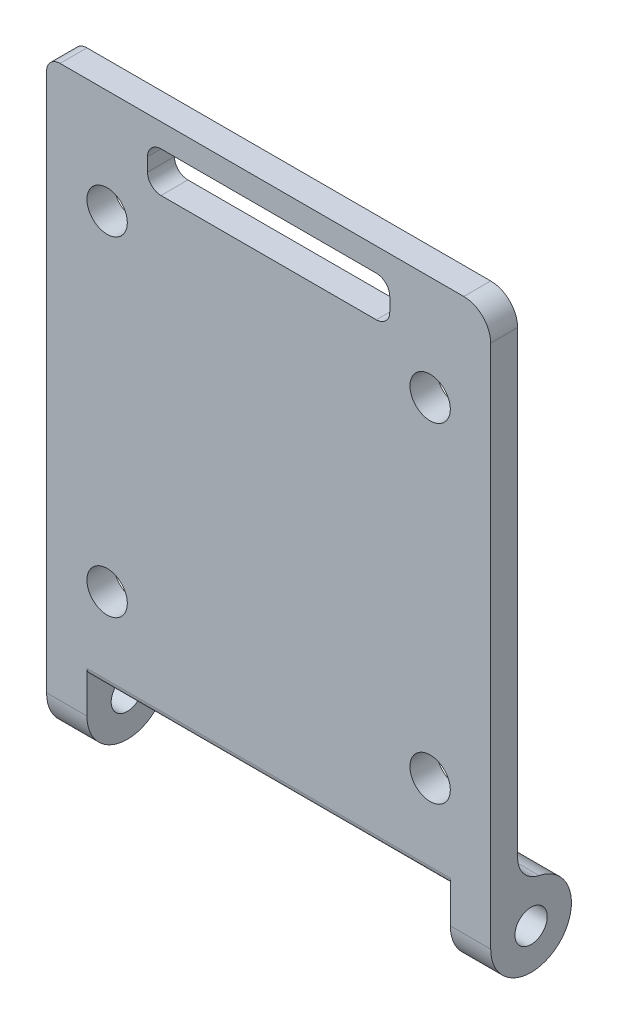
from build123d import *
from OCP.BRepFilletAPI import BRepFilletAPI_MakeFillet

# Parameters (mm, degrees)
SKETCH1_W               = 33
SKETCH1_H               = 40
BOSS_EXTRUDE1_DEPTH     = 1
SKETCH3_R               = 1.2
BOSS_EXTRUDE2_DEPTH     = 3
BOSS_EXTRUDE3_START     = -3
SKETCH4_R               = 1.2
BOSS_EXTRUDE3_DEPTH     = 3
CUT_EXTRUDE1_DEPTH      = 30.550803712
CUT_EXTRUDE1_DEPTH_BACK = 30.550803712
SKETCH6_R               = 1.5
SKETCH6_W               = 18
SKETCH6_H               = 3
FILLET4_R1              = 2
FILLET4_R2              = 1
CUT_EXTRUDE2_DEPTH      = 27
FILLET5_R               = 0.5


with BuildPart() as part:
    # Sketch1 → Boss-Extrude1 (new, symmetric)
    with BuildSketch(Plane.XY):
        Rectangle(SKETCH1_W, SKETCH1_H)
    extrude(amount=BOSS_EXTRUDE1_DEPTH, both=True)

    # Sketch3 → Boss-Extrude2 (add)
    with BuildSketch(Plane(origin=(16.5, 0, 0), x_dir=(0, 0, -1), z_dir=(1, 0, 0))):
        with BuildLine():
            Line((-1, -20), (-1, -21))
            ThreePointArc((-1, -21), (4.449489743, -22.732050808), (1, -18.171572875))
            Line((1, -18.171572875), (-1, -20))
        make_face()
        with Locations((2, -21)):
            Circle(SKETCH3_R, mode=Mode.SUBTRACT)
    extrude(amount=-BOSS_EXTRUDE2_DEPTH)

    # Sketch4 → Boss-Extrude3 (add)
    with BuildSketch(Plane.ZY.offset(16.5).offset(BOSS_EXTRUDE3_START)):
        with BuildLine():
            Line((1, -20), (1, -21))
            ThreePointArc((1, -21), (-4.449489743, -22.732050808), (-1, -18.171572875))
            Line((-1, -18.171572875), (1, -20))
        make_face()
        with Locations(Location((-2, -21, 0), (0, 0, 180))):
            Circle(SKETCH4_R, mode=Mode.SUBTRACT)
    extrude(amount=BOSS_EXTRUDE3_DEPTH)

    # Sketch6 → Cut-Extrude1 (cut, two sides: drawn at the far end of the back side and taken through both)
    with BuildSketch(Plane.XY.offset(-CUT_EXTRUDE1_DEPTH_BACK)):
        with Locations((-12, 12.25)):
            Circle(SKETCH6_R)
        with Locations((12, 12.25)):
            Circle(SKETCH6_R)
        with Locations((12, -12.25)):
            Circle(SKETCH6_R)
        with Locations((-12, -12.25)):
            Circle(SKETCH6_R)
        with Locations((0, 16.75)):
            Rectangle(SKETCH6_W, SKETCH6_H)
    extrude(amount=CUT_EXTRUDE1_DEPTH + CUT_EXTRUDE1_DEPTH_BACK, mode=Mode.SUBTRACT)

    # Fillet4: one fillet with a radius per group of edges: ONE call of the kernel's fillet builder (fillet() takes one radius for all edges)
    fillet4_edges_1 = [part.edges().sort_by_distance(p)[0] for p in [
        (16.5, 20, 0),
        (15, -18.171572875, -1),
        (-15, -18.171572875, -1),
    ]]
    fillet4_edges_2 = [part.edges().sort_by_distance(p)[0] for p in [
        (-16.5, 20, 0),
        (-9, 18.25, 0),
        (-9, 15.25, 0),
        (9, 18.25, 0),
        (9, 15.25, 0),
    ]]
    fillet4 = BRepFilletAPI_MakeFillet(part.part.solid().wrapped)
    for e in fillet4_edges_1:
        fillet4.Add(FILLET4_R1, e.wrapped)
    for e in fillet4_edges_2:
        fillet4.Add(FILLET4_R2, e.wrapped)
    add(Compound.cast(fillet4.Shape()), mode=Mode.REPLACE)

    # Sketch8 → Cut-Extrude2 (cut)
    with BuildSketch(Plane.ZY.offset(-13.5)):
        Polygon((-1, -16.101020514), (1, -20), (-1, -20), align=None)
    extrude(amount=CUT_EXTRUDE2_DEPTH, mode=Mode.SUBTRACT)

    # Fillet5
    fillet5_edges = [part.edges().sort_by_distance(p)[0] for p in [
        (0, -20, 1),
    ]]
    fillet(fillet5_edges, radius=FILLET5_R)


solid = part.part
